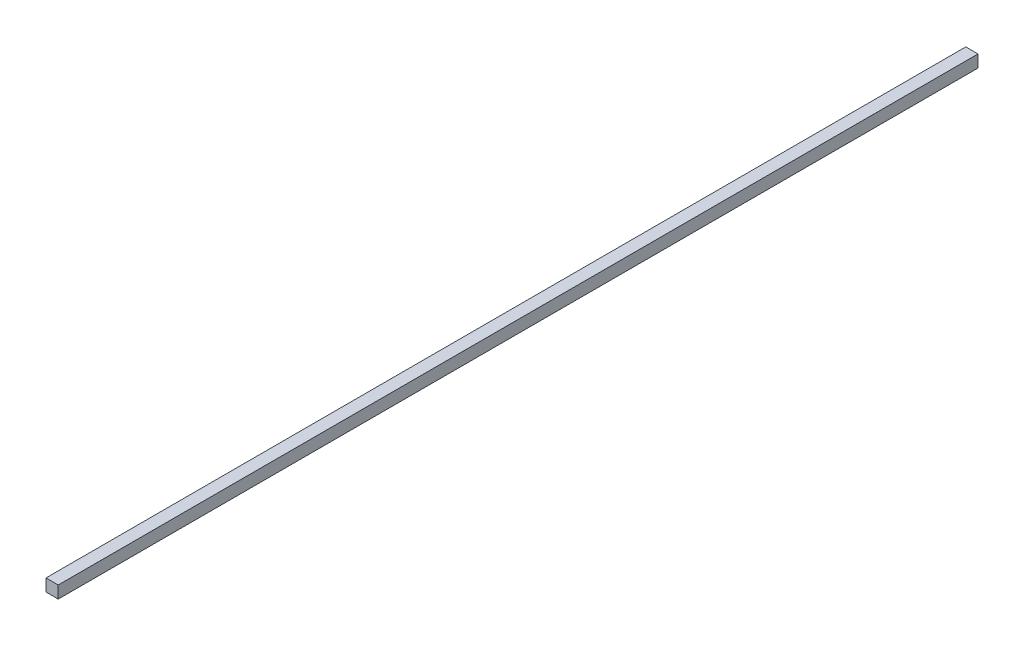
from build123d import *

# Parameters (mm, degrees)
SKETCH1_W           = 3.3782
SKETCH1_H           = 3.3782
BOSS_EXTRUDE1_DEPTH = 254


with BuildPart() as part:
    # Sketch1 → Boss-Extrude1 (new body)
    with BuildSketch(Plane.XY):
        Rectangle(SKETCH1_W, SKETCH1_H)
    extrude(amount=BOSS_EXTRUDE1_DEPTH)


solid = part.part
